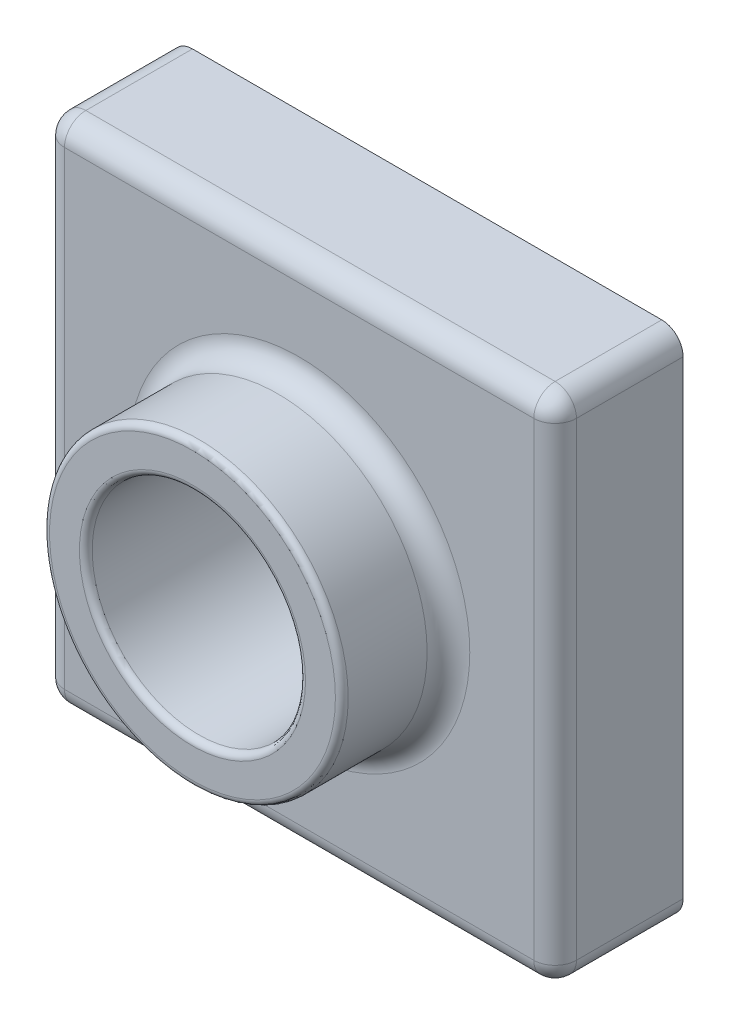
from build123d import *

# Parameters (mm, degrees)
SKETCH1_W           = 120
SKETCH1_H           = 120
BOSS_EXTRUDE1_DEPTH = 30
SKETCH3_R           = 35
BOSS_EXTRUDE2_DEPTH = 25
SKETCH4_R           = 25
CUT_EXTRUDE1_DEPTH  = 179.395627749
FILLET1_R           = 5
FILLET2_R           = 1.5
SHELL1_T            = -2


with BuildPart() as part:
    # Sketch1 → Boss-Extrude1 (new body)
    with BuildSketch(Plane.XY):
        with Locations((60, 60)):
            Rectangle(SKETCH1_W, SKETCH1_H)
    extrude(amount=BOSS_EXTRUDE1_DEPTH)

    # Sketch3 → Boss-Extrude2 (add)
    with BuildSketch(Plane.XY.offset(30)):
        with Locations((60, 60)):
            Circle(SKETCH3_R)
    extrude(amount=BOSS_EXTRUDE2_DEPTH)

    # Sketch4 → Cut-Extrude1 (cut, through all)
    with BuildSketch(Plane.XY.offset(55)):
        with Locations((60, 60)):
            Circle(SKETCH4_R)
    extrude(amount=-CUT_EXTRUDE1_DEPTH, mode=Mode.SUBTRACT)

    # Fillet1
    fillet1_edges = [part.edges().sort_by_distance(p)[0] for p in [
        (120, 60, 30),
        (25, 60, 30),
        (60, 120, 30),
        (0, 60, 30),
        (0, 120, 15),
        (120, 120, 15),
        (120, 0, 15),
        (0, 0, 15),
        (60, 0, 30),
    ]]
    fillet(fillet1_edges, radius=FILLET1_R)

    # Fillet2
    fillet2_edges = [part.edges().sort_by_distance(p)[0] for p in [
        (25, 60, 55),
        (35, 60, 55),
    ]]
    fillet(fillet2_edges, radius=FILLET2_R)

    # Shell1
    shell1_openings = [part.faces().sort_by_distance(p)[0] for p in [
        (60, 118.302943725, 0),
    ]]
    offset(amount=SHELL1_T, openings=shell1_openings, kind=Kind.INTERSECTION)


solid = part.part
